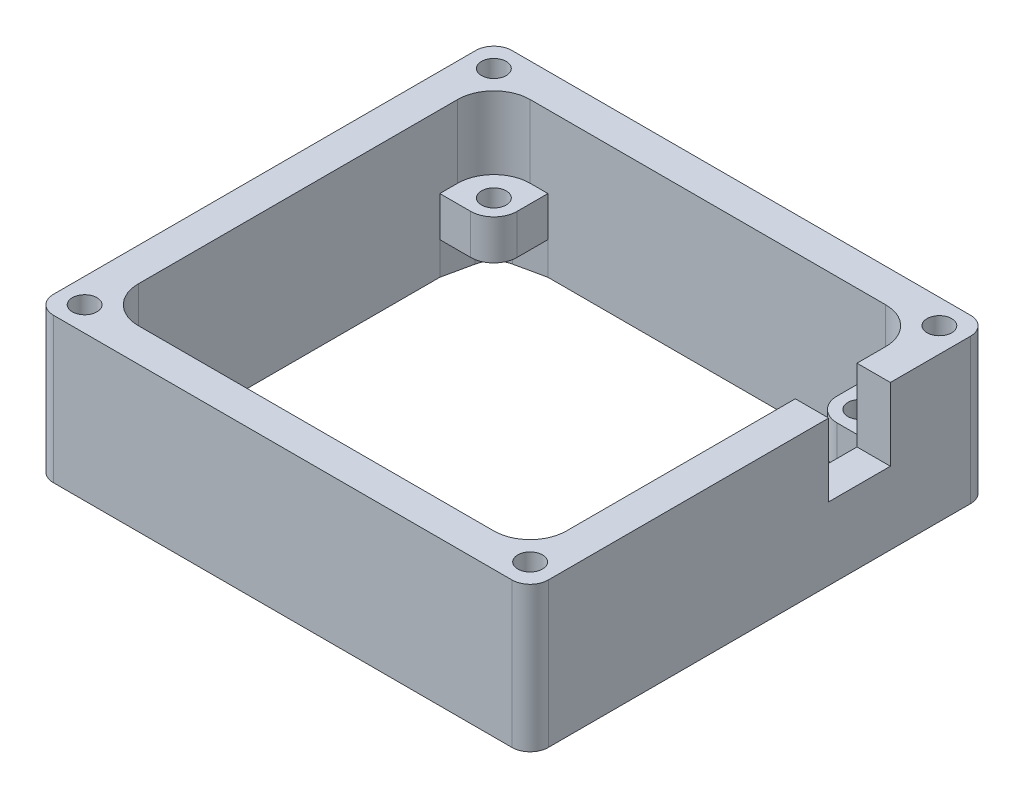
from build123d import *

# Parameters (mm, degrees)
EXTRUDE_2_DEPTH     = 20
EXTRUDE_3_DEPTH     = 4
EXTRUDE_4_DEPTH     = 10
CUT_EXTRUDE_1_DEPTH = 25
SKETCH_5_W          = 4.6
SKETCH_5_H          = 8.5
CUT_EXTRUDE_2_DEPTH = 10
CUT_EXTRUDE_3_DEPTH = 4
SKETCH_7_R          = 1.7
CUT_EXTRUDE_4_DEPTH = 4.5


with BuildPart() as part:
    # ｽｹｯﾁ1 → ﾎﾞｽ - 押し出し2 (new body)
    with BuildSketch(Plane(origin=(0, 0, 0), x_dir=(1, 0, 0), z_dir=(0, 1, 0))):
        with BuildLine():
            Line((31.6, 31.6), (-31.6, 31.6))
            ThreePointArc((-31.6, 31.6), (-33.367766953, 30.867766953), (-34.1, 29.1))
            Line((-34.1, 29.1), (-34.1, -29.1))
            ThreePointArc((-34.1, -29.1), (-33.367766953, -30.867766953), (-31.6, -31.6))
            Line((-31.6, -31.6), (31.6, -31.6))
            ThreePointArc((31.6, -31.6), (33.367766953, -30.867766953), (34.1, -29.1))
            Line((34.1, -29.1), (34.1, 29.1))
            ThreePointArc((34.1, 29.1), (33.367766953, 30.867766953), (31.6, 31.6))
        make_face()
        with BuildLine():
            Line((24.5, 27), (-24.5, 27))
            ThreePointArc((-24.5, 27), (-28.035533906, 25.535533906), (-29.5, 22))
            Line((-29.5, 22), (-29.5, -22))
            ThreePointArc((-29.5, -22), (-28.035533906, -25.535533906), (-24.5, -27))
            Line((-24.5, -27), (24.5, -27))
            ThreePointArc((24.5, -27), (28.035533906, -25.535533906), (29.5, -22))
            Line((29.5, -22), (29.5, 22))
            ThreePointArc((29.5, 22), (28.035533906, 25.535533906), (24.5, 27))
        make_face(mode=Mode.SUBTRACT)
    extrude(amount=EXTRUDE_2_DEPTH)

    # ｽｹｯﾁ2 → ﾎﾞｽ - 押し出し3 (add)
    with BuildSketch(Plane.XZ):
        with BuildLine():
            Line((34.1, -29.1), (34.1, 29.1))
            ThreePointArc((34.1, 29.1), (33.367766953, 30.867766953), (31.6, 31.6))
            Line((31.6, 31.6), (-31.6, 31.6))
            ThreePointArc((-31.6, 31.6), (-33.367766953, 30.867766953), (-34.1, 29.1))
            Line((-34.1, 29.1), (-34.1, -29.1))
            ThreePointArc((-34.1, -29.1), (-33.367766953, -30.867766953), (-31.6, -31.6))
            Line((-31.6, -31.6), (31.6, -31.6))
            ThreePointArc((31.6, -31.6), (33.367766953, -30.867766953), (34.1, -29.1))
        make_face()
    extrude(amount=EXTRUDE_3_DEPTH)

    # ｽｹｯﾁ3 → ﾎﾞｽ - 押し出し4 (add)
    with BuildSketch(Plane(origin=(0, 0, 0), x_dir=(1, 0, 0), z_dir=(0, 1, 0))):
        with BuildLine():
            ThreePointArc((22.05, 22.75), (22.9872583, 20.4872583), (25.25, 19.55))
            Line((25.25, 19.55), (25.25, 21.05))
            ThreePointArc((25.25, 21.05), (24.047918472, 21.547918472), (23.55, 22.75))
            Line((23.55, 22.75), (22.05, 22.75))
        make_face()
        with BuildLine():
            Line((25.25, 21.05), (25.25, 19.55))
            ThreePointArc((25.25, 19.55), (27.5127417, 20.4872583), (28.45, 22.75))
            ThreePointArc((28.45, 22.75), (25.25, 25.95), (22.05, 22.75))
            Line((22.05, 22.75), (23.55, 22.75))
            ThreePointArc((23.55, 22.75), (25.25, 24.45), (26.95, 22.75))
            ThreePointArc((26.95, 22.75), (26.452081528, 21.547918472), (25.25, 21.05))
        make_face()
        with BuildLine():
            ThreePointArc((-22.05, 22.75), (-27.5127417, 25.0127417), (-25.25, 19.55))
            Line((-25.25, 19.55), (-25.25, 21.05))
            ThreePointArc((-25.25, 21.05), (-26.452081528, 23.952081528), (-23.55, 22.75))
            Line((-23.55, 22.75), (-22.05, 22.75))
        make_face()
        with BuildLine():
            Line((-25.25, 21.05), (-25.25, 19.55))
            ThreePointArc((-25.25, 19.55), (-22.9872583, 20.4872583), (-22.05, 22.75))
            Line((-22.05, 22.75), (-23.55, 22.75))
            ThreePointArc((-23.55, 22.75), (-24.047918472, 21.547918472), (-25.25, 21.05))
        make_face()
        with BuildLine():
            ThreePointArc((-25.25, -21.05), (-24.047918472, -21.547918472), (-23.55, -22.75))
            Line((-23.55, -22.75), (-22.05, -22.75))
            ThreePointArc((-22.05, -22.75), (-22.9872583, -20.4872583), (-25.25, -19.55))
            Line((-25.25, -19.55), (-25.25, -21.05))
        make_face()
        with BuildLine():
            Line((-22.05, -22.75), (-23.55, -22.75))
            ThreePointArc((-23.55, -22.75), (-26.452081528, -23.952081528), (-25.25, -21.05))
            Line((-25.25, -21.05), (-25.25, -19.55))
            ThreePointArc((-25.25, -19.55), (-27.5127417, -25.0127417), (-22.05, -22.75))
        make_face()
        with BuildLine():
            ThreePointArc((25.25, -19.55), (22.987258299, -20.487258301), (22.05, -22.750000003))
            Line((22.05, -22.75), (23.55, -22.75))
            ThreePointArc((23.55, -22.75), (24.047918472, -21.547918472), (25.25, -21.05))
            Line((25.25, -21.05), (25.25, -19.55))
        make_face()
        with BuildLine():
            Line((23.55, -22.75), (22.05, -22.75))
            ThreePointArc((22.05, -22.750000003), (25.250000002, -25.95), (28.45, -22.75))
            ThreePointArc((28.45, -22.75), (27.5127417, -20.4872583), (25.25, -19.55))
            Line((25.25, -19.55), (25.25, -21.05))
            ThreePointArc((25.25, -21.05), (26.452081528, -21.547918472), (26.95, -22.75))
            ThreePointArc((26.95, -22.75), (25.25, -24.45), (23.55, -22.75))
        make_face()
        with BuildLine():
            ThreePointArc((28.45, -22.75), (25.250000002, -25.95), (22.05, -22.750000003))
            Line((22.05, -22.750000003), (22.05, -27))
            Line((22.05, -27), (24.5, -27))
            ThreePointArc((24.5, -27), (28.035533906, -25.535533906), (29.5, -22))
            Line((29.5, -22), (29.5, -19.55))
            Line((29.5, -19.55), (25.25, -19.55))
            ThreePointArc((25.25, -19.55), (27.5127417, -20.4872583), (28.45, -22.75))
        make_face()
        with BuildLine():
            ThreePointArc((28.45, 22.75), (27.5127417, 20.4872583), (25.25, 19.55))
            Line((25.25, 19.55), (29.5, 19.55))
            Line((29.5, 19.55), (29.5, 22))
            ThreePointArc((29.5, 22), (28.035533906, 25.535533906), (24.5, 27))
            Line((24.5, 27), (22.05, 27))
            Line((22.05, 27), (22.05, 22.75))
            ThreePointArc((22.05, 22.75), (25.25, 25.95), (28.45, 22.75))
        make_face()
        with BuildLine():
            Line((-22.05, -27), (-22.05, -22.75))
            ThreePointArc((-22.05, -22.75), (-27.5127417, -25.0127417), (-25.25, -19.55))
            Line((-25.25, -19.55), (-29.5, -19.55))
            Line((-29.5, -19.55), (-29.5, -22))
            ThreePointArc((-29.5, -22), (-28.035533906, -25.535533906), (-24.5, -27))
            Line((-24.5, -27), (-22.05, -27))
        make_face()
        with BuildLine():
            Line((-29.5, 19.55), (-25.25, 19.55))
            ThreePointArc((-25.25, 19.55), (-27.5127417, 25.0127417), (-22.05, 22.75))
            Line((-22.05, 22.75), (-22.05, 27))
            Line((-22.05, 27), (-24.5, 27))
            ThreePointArc((-24.5, 27), (-28.035533906, 25.535533906), (-29.5, 22))
            Line((-29.5, 22), (-29.5, 19.55))
        make_face()
    extrude(amount=EXTRUDE_4_DEPTH)

    # ｽｹｯﾁ4 → ｶｯﾄ - 押し出し1 (cut, through all)
    with BuildSketch(Plane(origin=(0, 20, 0), x_dir=(1, 0, 0), z_dir=(0, 1, 0))):
        with BuildLine():
            ThreePointArc((-29.499568901, -26.999568901), (-31.903731957, -26.999568901), (-31.903731957, -29.403731957))
            Line((-31.903731957, -29.403731957), (-29.499568901, -26.999568901))
        make_face()
        with BuildLine():
            Line((-29.499568901, -26.999568901), (-31.903731957, -29.403731957))
            ThreePointArc((-31.903731957, -29.403731957), (-30.051088594, -29.772245635), (-29.001650429, -28.201650429))
            ThreePointArc((-29.001650429, -28.201650429), (-29.131055224, -27.551088594), (-29.499568901, -26.999568901))
        make_face()
        with BuildLine():
            ThreePointArc((-31.903731957, 29.403731957), (-31.903731957, 26.999568901), (-29.499568901, 26.999568901))
            Line((-29.499568901, 26.999568901), (-31.903731957, 29.403731957))
        make_face()
        with BuildLine():
            Line((-31.903731957, 29.403731957), (-29.499568901, 26.999568901))
            ThreePointArc((-29.499568901, 26.999568901), (-29.131055224, 27.551088594), (-29.001650429, 28.201650429))
            ThreePointArc((-29.001650429, 28.201650429), (-30.051088594, 29.772245635), (-31.903731957, 29.403731957))
        make_face()
        with BuildLine():
            ThreePointArc((32.401650429, 28.201650429), (32.272245635, 28.852212264), (31.903731957, 29.403731957))
            Line((31.903731957, 29.403731957), (29.499568901, 26.999568901))
            ThreePointArc((29.499568901, 26.999568901), (31.352212264, 26.631055224), (32.401650429, 28.201650429))
        make_face()
        with BuildLine():
            Line((29.499568901, 26.999568901), (31.903731957, 29.403731957))
            ThreePointArc((31.903731957, 29.403731957), (29.499568901, 29.403731957), (29.499568901, 26.999568901))
        make_face()
        with BuildLine():
            ThreePointArc((32.401650429, -28.201650429), (31.352212264, -26.631055224), (29.499568901, -26.999568901))
            Line((29.499568901, -26.999568901), (31.903731957, -29.403731957))
            ThreePointArc((31.903731957, -29.403731957), (32.272245635, -28.852212264), (32.401650429, -28.201650429))
        make_face()
        with BuildLine():
            Line((31.903731957, -29.403731957), (29.499568901, -26.999568901))
            ThreePointArc((29.499568901, -26.999568901), (29.499568901, -29.403731957), (31.903731957, -29.403731957))
        make_face()
    extrude(amount=-CUT_EXTRUDE_1_DEPTH, mode=Mode.SUBTRACT)

    # ｽｹｯﾁ5 → ｶｯﾄ - 押し出し2 (cut)
    with BuildSketch(Plane(origin=(0, 20, 0), x_dir=(1, 0, 0), z_dir=(0, 1, 0))):
        with Locations((31.8, 13.8)):
            Rectangle(SKETCH_5_W, SKETCH_5_H)
    extrude(amount=-CUT_EXTRUDE_2_DEPTH, mode=Mode.SUBTRACT)

    # ｽｹｯﾁ6 → ｶｯﾄ - 押し出し3 (cut)
    with BuildSketch(Plane.XZ.offset(4)):
        with BuildLine():
            Line((34.1, -29.1), (34.1, 29.1))
            ThreePointArc((34.1, 29.1), (33.367766953, 30.867766953), (31.6, 31.6))
            Line((31.6, 31.6), (-31.6, 31.6))
            ThreePointArc((-31.6, 31.6), (-33.367766953, 30.867766953), (-34.1, 29.1))
            Line((-34.1, 29.1), (-34.1, -29.1))
            ThreePointArc((-34.1, -29.1), (-33.367766953, -30.867766953), (-31.6, -31.6))
            Line((-31.6, -31.6), (31.6, -31.6))
            ThreePointArc((31.6, -31.6), (33.367766953, -30.867766953), (34.1, -29.1))
        make_face()
    extrude(amount=-CUT_EXTRUDE_3_DEPTH, mode=Mode.SUBTRACT)

    # ｽｹｯﾁ7 → ｶｯﾄ - 押し出し4 (cut)
    with BuildSketch(Plane.XZ):
        with BuildLine():
            ThreePointArc((28.6333448, -23.565494429), (27.727552542, -25.227552542), (26.065494429, -26.1333448))
            Line((26.065494429, -26.1333448), (22.05, -27))
            Line((22.05, -27), (22.05, -22.75))
            ThreePointArc((22.05, -22.75), (22.9872583, -20.4872583), (25.25, -19.55))
            Line((25.25, -19.55), (29.5, -19.55))
            Line((29.5, -19.55), (28.6333448, -23.565494429))
        make_face()
        with Locations((25.25, -22.75)):
            Circle(SKETCH_7_R, mode=Mode.SUBTRACT)
        with BuildLine():
            Line((-29.5, -19.55), (-28.6333448, -23.565494429))
            ThreePointArc((-28.6333448, -23.565494429), (-27.727552542, -25.227552542), (-26.065494429, -26.1333448))
            Line((-26.065494429, -26.1333448), (-22.05, -27))
            Line((-22.05, -27), (-22.05, -22.75))
            ThreePointArc((-22.05, -22.75), (-22.9872583, -20.4872583), (-25.25, -19.55))
            Line((-25.25, -19.55), (-29.5, -19.55))
        make_face()
        with Locations((-25.25, -22.75)):
            Circle(SKETCH_7_R, mode=Mode.SUBTRACT)
        with BuildLine():
            ThreePointArc((-28.6333448, 23.565494429), (-27.727552542, 25.227552542), (-26.065494429, 26.1333448))
            Line((-26.065494429, 26.1333448), (-22.05, 27))
            Line((-22.05, 27), (-22.05, 22.75))
            ThreePointArc((-22.05, 22.75), (-22.9872583, 20.4872583), (-25.25, 19.55))
            Line((-25.25, 19.55), (-29.5, 19.55))
            Line((-29.5, 19.55), (-28.6333448, 23.565494429))
        make_face()
        with Locations((-25.25, 22.75)):
            Circle(SKETCH_7_R, mode=Mode.SUBTRACT)
        with BuildLine():
            Line((29.5, 19.55), (28.6333448, 23.565494429))
            ThreePointArc((28.6333448, 23.565494429), (27.727552542, 25.227552542), (26.065494429, 26.1333448))
            Line((26.065494429, 26.1333448), (22.05, 27))
            Line((22.05, 27), (22.05, 22.75))
            ThreePointArc((22.05, 22.75), (22.9872583, 20.4872583), (25.25, 19.55))
            Line((25.25, 19.55), (29.5, 19.55))
        make_face()
        with Locations((25.25, 22.75)):
            Circle(SKETCH_7_R, mode=Mode.SUBTRACT)
    extrude(amount=-CUT_EXTRUDE_4_DEPTH, mode=Mode.SUBTRACT)


solid = part.part
